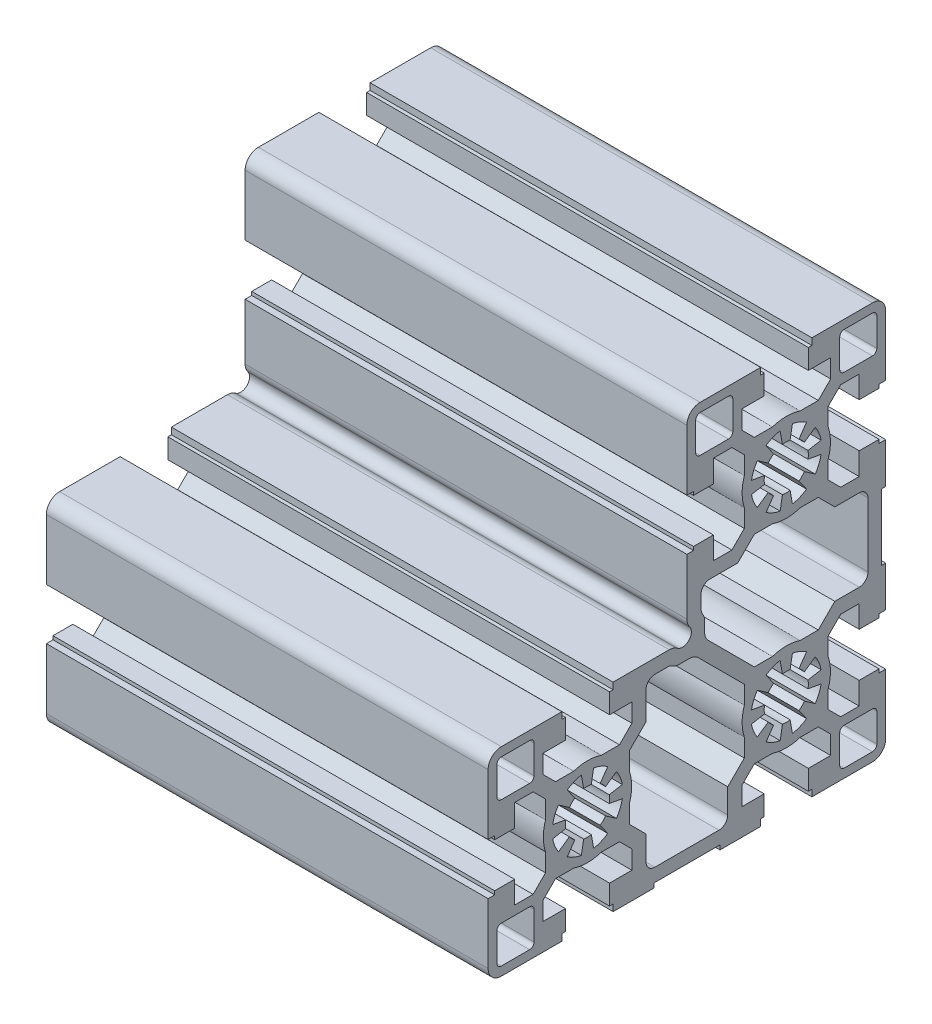
from build123d import *

# Parameters (mm, degrees)
EXTRUDE_1_DEPTH = 100


with BuildPart() as part:
    # Эскиз2 → Бобышка-Вытянуть1 (new body)
    with BuildSketch(Plane(origin=(0, 0, 0), x_dir=(0, 0, -1), z_dir=(1, 0, 0))):
        with BuildLine():
            Line((-67.500000003, -19.500000001), (-67.500000003, -5.800000001))
            Line((-67.500000003, -5.800000001), (-66.000000006, -5.800000001))
            Line((-66.000000006, -5.800000001), (-66.000000006, -5))
            Line((-66.000000006, -5), (-61.500000006, -5))
            Line((-61.500000006, -5), (-61.500000006, -10.05))
            Line((-61.500000006, -10.05), (-57.312741706, -10.05))
            Line((-57.312741706, -10.05), (-54.500000006, -7.2372583))
            Line((-54.500000006, -7.2372583), (-54.500000006, -3.122499))
            ThreePointArc((-54.500000006, -3.122499), (-55.000000006, 0), (-54.500000006, 3.122499))
            Line((-54.500000006, 3.122499), (-54.500000006, 7.2372583))
            Line((-54.500000006, 7.2372583), (-57.312741706, 10.05))
            Line((-57.312741706, 10.05), (-61.500000006, 10.05))
            Line((-61.500000006, 10.05), (-61.500000006, 4.999999999))
            Line((-61.500000006, 4.999999999), (-66.000000006, 4.999999999))
            Line((-66.000000006, 4.999999999), (-66.000000006, 5.799999999))
            Line((-66.000000006, 5.799999999), (-67.500000003, 5.799999999))
            Line((-67.500000003, 5.799999999), (-67.500000003, 19.499999999))
            ThreePointArc((-67.500000003, 19.499999999), (-66.621320347, 21.621320343), (-64.500000003, 22.499999999))
            Line((-64.500000003, 22.499999999), (-50.800000006, 22.499999999))
            Line((-50.800000006, 22.499999999), (-50.800000006, 21))
            Line((-50.800000006, 21), (-50.000000006, 21))
            Line((-50.000000006, 21), (-50.000000006, 16.5))
            Line((-50.000000006, 16.5), (-55.050000006, 16.5))
            Line((-55.050000006, 16.5), (-55.050000006, 12.3127417))
            Line((-55.050000006, 12.3127417), (-52.237258306, 9.5))
            Line((-52.237258306, 9.5), (-48.122499006, 9.5))
            ThreePointArc((-48.122499006, 9.5), (-45.000000006, 10), (-41.877501006, 9.5))
            Line((-41.877501006, 9.5), (-37.762741706, 9.5))
            Line((-37.762741706, 9.5), (-34.950000006, 12.3127417))
            Line((-34.950000006, 12.3127417), (-34.950000006, 16.5))
            Line((-34.950000006, 16.5), (-40.000000006, 16.5))
            Line((-40.000000006, 16.5), (-40.000000006, 21))
            Line((-40.000000006, 21), (-39.200000006, 21))
            Line((-39.200000006, 21), (-39.200000006, 22.5))
            Line((-39.200000006, 22.5), (-26.503303616, 22.5))
            ThreePointArc((-26.503303616, 22.5), (-25.549864863, 22.344460326), (-24.695291146, 21.893969697))
            ThreePointArc((-24.695291146, 21.893969697), (-22.075735937, 22.075735932), (-21.8939697, 24.695291141))
            ThreePointArc((-21.8939697, 24.695291141), (-22.344460329, 25.549864857), (-22.500000002, 26.503303609))
            Line((-22.500000002, 26.503303609), (-22.500000002, 39.199999999))
            Line((-22.500000002, 39.199999999), (-21, 39.199999999))
            Line((-21, 39.199999999), (-21, 39.999999998))
            Line((-21, 39.999999998), (-16.500000023, 39.999999998))
            Line((-16.500000023, 39.999999998), (-16.500000023, 34.949999998))
            Line((-16.500000023, 34.949999998), (-12.312741723, 34.949999998))
            Line((-12.312741723, 34.949999998), (-9.500000023, 37.762741698))
            Line((-9.500000023, 37.762741698), (-9.500000023, 41.877500998))
            ThreePointArc((-9.500000023, 41.877500998), (-10.000000023, 44.999999998), (-9.500000023, 48.122498998))
            Line((-9.500000023, 48.122498998), (-9.500000023, 52.237258298))
            Line((-9.500000023, 52.237258298), (-12.312741723, 55.049999998))
            Line((-12.312741723, 55.049999998), (-16.500000003, 55.049999998))
            Line((-16.500000003, 55.049999998), (-16.500000003, 49.999999999))
            Line((-16.500000003, 49.999999999), (-21.000000003, 49.999999999))
            Line((-21.000000003, 49.999999999), (-21.000000003, 50.799999999))
            Line((-21.000000003, 50.799999999), (-22.500000003, 50.799999999))
            Line((-22.500000003, 50.799999999), (-22.500000003, 64.499999999))
            ThreePointArc((-22.500000003, 64.499999999), (-21.621320347, 66.621320343), (-19.500000003, 67.499999999))
            Line((-19.500000003, 67.499999999), (-5.800000023, 67.499999999))
            Line((-5.800000023, 67.499999999), (-5.800000023, 65.999999998))
            Line((-5.800000023, 65.999999998), (-5.000000023, 65.999999998))
            Line((-5.000000023, 65.999999998), (-5.000000023, 61.499999998))
            Line((-5.000000023, 61.499999998), (-10.050000023, 61.499999998))
            Line((-10.050000023, 61.499999998), (-10.050000023, 57.312741698))
            Line((-10.050000023, 57.312741698), (-7.237258323, 54.499999998))
            Line((-7.237258323, 54.499999998), (-3.122499023, 54.499999998))
            ThreePointArc((-3.122499023, 54.499999998), (-2.3e-08, 54.999999999), (3.122498977, 54.499999998))
            Line((3.122498977, 54.499999998), (7.237258277, 54.499999998))
            Line((7.237258277, 54.499999998), (10.049999977, 57.312741698))
            Line((10.049999977, 57.312741698), (10.049999977, 61.499999998))
            Line((10.049999977, 61.499999998), (4.999999977, 61.499999998))
            Line((4.999999977, 61.499999998), (4.999999977, 65.999999998))
            Line((4.999999977, 65.999999998), (5.799999977, 65.999999998))
            Line((5.799999977, 65.999999998), (5.799999977, 67.499999999))
            Line((5.799999977, 67.499999999), (19.499999997, 67.499999999))
            ThreePointArc((19.499999997, 67.499999999), (21.621320341, 66.621320343), (22.499999997, 64.499999999))
            Line((22.499999997, 64.499999999), (22.499999997, 50.799999999))
            Line((22.499999997, 50.799999999), (20.999999997, 50.799999999))
            Line((20.999999997, 50.799999999), (20.999999997, 49.999999999))
            Line((20.999999997, 49.999999999), (16.499999997, 49.999999999))
            Line((16.499999997, 49.999999999), (16.499999997, 55.049999998))
            Line((16.499999997, 55.049999998), (12.312741677, 55.049999998))
            Line((12.312741677, 55.049999998), (9.499999977, 52.237258298))
            Line((9.499999977, 52.237258298), (9.499999977, 48.122498998))
            ThreePointArc((9.499999977, 48.122498998), (9.999999977, 44.999999998), (9.499999977, 41.877500998))
            Line((9.499999977, 41.877500998), (9.499999977, 37.762741698))
            Line((9.499999977, 37.762741698), (12.312741677, 34.949999998))
            Line((12.312741677, 34.949999998), (16.499999977, 34.949999998))
            Line((16.499999977, 34.949999998), (16.499999977, 40))
            Line((16.499999977, 40), (21, 40))
            Line((21, 40), (21, 39.2))
            Line((21, 39.2), (22.5, 39.2))
            Line((22.5, 39.2), (22.5, 30))
            Line((22.5, 30), (21.5, 30))
            Line((21.5, 30), (21.5, 15))
            Line((21.5, 15), (22.5, 15))
            Line((22.5, 15), (22.5, 5.8))
            Line((22.5, 5.8), (21, 5.8))
            Line((21, 5.8), (21, 5))
            Line((21, 5), (16.5, 5))
            Line((16.5, 5), (16.5, 10.05))
            Line((16.5, 10.05), (12.3127417, 10.05))
            Line((12.3127417, 10.05), (9.5, 7.2372583))
            Line((9.5, 7.2372583), (9.5, 3.122499))
            ThreePointArc((9.5, 3.122499), (10, 0), (9.5, -3.122499))
            Line((9.5, -3.122499), (9.5, -7.2372583))
            Line((9.5, -7.2372583), (12.3127417, -10.05))
            Line((12.3127417, -10.05), (16.5, -10.05))
            Line((16.5, -10.05), (16.5, -5.000000001))
            Line((16.5, -5.000000001), (20.999999997, -5.000000001))
            Line((20.999999997, -5.000000001), (20.999999997, -5.800000001))
            Line((20.999999997, -5.800000001), (22.499999997, -5.800000001))
            Line((22.499999997, -5.800000001), (22.499999997, -19.500000001))
            ThreePointArc((22.499999997, -19.500000001), (21.621320341, -21.621320345), (19.499999997, -22.500000001))
            Line((19.499999997, -22.500000001), (5.799999997, -22.500000001))
            Line((5.799999997, -22.500000001), (5.799999997, -21.000000001))
            Line((5.799999997, -21.000000001), (4.999999997, -21.000000001))
            Line((4.999999997, -21.000000001), (4.999999997, -16.5))
            Line((4.999999997, -16.5), (10.05, -16.5))
            Line((10.05, -16.5), (10.05, -12.3127417))
            Line((10.05, -12.3127417), (7.2372583, -9.5))
            Line((7.2372583, -9.5), (3.122499, -9.5))
            ThreePointArc((3.122499, -9.5), (0, -10), (-3.122499, -9.5))
            Line((-3.122499, -9.5), (-7.2372583, -9.5))
            Line((-7.2372583, -9.5), (-10.05, -12.3127417))
            Line((-10.05, -12.3127417), (-10.05, -16.5))
            Line((-10.05, -16.5), (-5, -16.5))
            Line((-5, -16.5), (-5, -21))
            Line((-5, -21), (-5.8, -21))
            Line((-5.8, -21), (-5.8, -22.5))
            Line((-5.8, -22.5), (-15, -22.5))
            Line((-15, -22.5), (-15, -21.5))
            Line((-15, -21.5), (-30, -21.5))
            Line((-30, -21.5), (-30, -22.5))
            Line((-30, -22.5), (-39.2, -22.5))
            Line((-39.2, -22.5), (-39.2, -21))
            Line((-39.2, -21), (-40, -21))
            Line((-40, -21), (-40, -16.5))
            Line((-40, -16.5), (-34.950000006, -16.5))
            Line((-34.950000006, -16.5), (-34.950000006, -12.3127417))
            Line((-34.950000006, -12.3127417), (-37.762741706, -9.5))
            Line((-37.762741706, -9.5), (-41.877501006, -9.5))
            ThreePointArc((-41.877501006, -9.5), (-45.000000006, -10), (-48.122499006, -9.5))
            Line((-48.122499006, -9.5), (-52.237258306, -9.5))
            Line((-52.237258306, -9.5), (-55.050000006, -12.3127417))
            Line((-55.050000006, -12.3127417), (-55.050000006, -16.500000001))
            Line((-55.050000006, -16.500000001), (-50.000000003, -16.500000001))
            Line((-50.000000003, -16.500000001), (-50.000000003, -21.000000001))
            Line((-50.000000003, -21.000000001), (-50.800000003, -21.000000001))
            Line((-50.800000003, -21.000000001), (-50.800000003, -22.500000001))
            Line((-50.800000003, -22.500000001), (-64.500000003, -22.500000001))
            ThreePointArc((-64.500000003, -22.500000001), (-66.621320347, -21.621320345), (-67.500000003, -19.500000001))
        make_face()
        with BuildLine():
            Line((13.099999997, 65.499999999), (19.499999997, 65.499999999))
            ThreePointArc((19.499999997, 65.499999999), (20.207106778, 65.20710678), (20.499999997, 64.499999999))
            Line((20.499999997, 64.499999999), (20.499999997, 58.099999999))
            ThreePointArc((20.499999997, 58.099999999), (20.207106778, 57.392893218), (19.499999997, 57.099999999))
            Line((19.499999997, 57.099999999), (13.099999997, 57.099999999))
            ThreePointArc((13.099999997, 57.099999999), (12.392893216, 57.392893218), (12.099999997, 58.099999999))
            Line((12.099999997, 58.099999999), (12.099999997, 64.499999999))
            ThreePointArc((12.099999997, 64.499999999), (12.392893216, 65.20710678), (13.099999997, 65.499999999))
        make_face(mode=Mode.SUBTRACT)
        with BuildLine():
            Line((-18.763513725, 25.405955913), (-19.036486289, 25.883657888))
            ThreePointArc((-19.036486289, 25.883657888), (-19.232999307, 26.362599899), (-19.300000011, 26.875935775))
            Line((-19.300000011, 26.875935775), (-19.300000011, 29.749569695))
            ThreePointArc((-19.300000011, 29.749569695), (-18.714213574, 31.163783257), (-17.300000012, 31.749569695))
            Line((-17.300000012, 31.749569695), (-10.987688612, 31.749569695))
            Line((-10.987688612, 31.749569695), (-7.237258312, 35.499999995))
            Line((-7.237258312, 35.499999995), (-3.122499012, 35.499999995))
            ThreePointArc((-3.122499012, 35.499999995), (-1e-08, 34.999999998), (3.122498991, 35.500000003))
            Line((3.122498991, 35.500000003), (7.237258291, 35.500000003))
            Line((7.237258291, 35.500000003), (10.987688591, 31.749569703))
            Line((10.987688591, 31.749569703), (16.499999991, 31.749569703))
            ThreePointArc((16.499999991, 31.749569703), (17.914213553, 31.163783265), (18.499999991, 29.749569703))
            Line((18.499999991, 29.749569703), (18.499999991, 15.250000003))
            ThreePointArc((18.499999991, 15.250000003), (17.914213553, 13.835786441), (16.499999991, 13.250000003))
            Line((16.499999991, 13.250000003), (10.987258291, 13.250000003))
            Line((10.987258291, 13.250000003), (7.237258291, 9.500000003))
            Line((7.237258291, 9.500000003), (3.122498991, 9.500000003))
            ThreePointArc((3.122498991, 9.500000003), (-9e-09, 10), (-3.122499009, 9.499999997))
            Line((-3.122499009, 9.499999997), (-7.237258309, 9.499999997))
            Line((-7.237258309, 9.499999997), (-17.621320349, 19.884062037))
            ThreePointArc((-17.621320349, 19.884062037), (-18.271638602, 20.857332083), (-18.500000003, 22.00538238))
            Line((-18.500000003, 22.00538238), (-18.500000003, 24.413678025))
            ThreePointArc((-18.500000003, 24.413678025), (-18.567000707, 24.927013902), (-18.763513725, 25.405955913))
        make_face(mode=Mode.SUBTRACT)
        with BuildLine():
            Line((-7.878462043, 43.610814578), (-4.924038783, 44.131759108))
            ThreePointArc((-4.924038783, 44.131759108), (-5.000000018, 44.999999998), (-4.924038783, 45.868240888))
            Line((-4.924038783, 45.868240888), (-7.878462043, 46.389185418))
            ThreePointArc((-7.878462043, 46.389185418), (-7.391036279, 48.061467456), (-6.553216373, 49.588611488))
            Line((-6.553216373, 49.588611488), (-4.095760243, 47.867882178))
            ThreePointArc((-4.095760243, 47.867882178), (-3.535533927, 48.535533903), (-2.867882203, 49.095760218))
            Line((-2.867882203, 49.095760218), (-4.588611513, 51.553216348))
            ThreePointArc((-4.588611513, 51.553216348), (-3.061467481, 52.391036255), (-1.389185443, 52.878462019))
            Line((-1.389185443, 52.878462019), (-0.868240913, 49.924038758))
            ThreePointArc((-0.868240913, 49.924038758), (-2.3e-08, 49.999999994), (0.868240867, 49.924038758))
            Line((0.868240867, 49.924038758), (1.389185397, 52.878462018))
            ThreePointArc((1.389185397, 52.878462018), (3.061467435, 52.391036254), (4.588611467, 51.553216348))
            Line((4.588611467, 51.553216348), (2.867882157, 49.095760218))
            ThreePointArc((2.867882157, 49.095760218), (3.535533882, 48.535533903), (4.095760197, 47.867882178))
            Line((4.095760197, 47.867882178), (6.553216327, 49.588611488))
            ThreePointArc((6.553216327, 49.588611488), (7.391036233, 48.061467456), (7.878461997, 46.389185418))
            Line((7.878461997, 46.389185418), (4.924038737, 45.868240888))
            ThreePointArc((4.924038737, 45.868240888), (4.999999972, 44.999999998), (4.924038737, 44.131759108))
            Line((4.924038737, 44.131759108), (7.878461997, 43.610814578))
            ThreePointArc((7.878461997, 43.610814578), (7.391036233, 41.938532541), (6.553216327, 40.411388509))
            Line((6.553216327, 40.411388509), (4.095760197, 42.132117818))
            ThreePointArc((4.095760197, 42.132117818), (3.535533882, 41.464466094), (2.867882157, 40.904239778))
            Line((2.867882157, 40.904239778), (4.588611467, 38.446783648))
            ThreePointArc((4.588611467, 38.446783648), (3.061467435, 37.608963742), (1.389185397, 37.121537978))
            Line((1.389185397, 37.121537978), (0.868240867, 40.075961238))
            ThreePointArc((0.868240867, 40.075961238), (-2.3e-08, 40.000000003), (-0.868240913, 40.075961238))
            Line((-0.868240913, 40.075961238), (-1.389185443, 37.121537978))
            ThreePointArc((-1.389185443, 37.121537978), (-3.061467481, 37.608963743), (-4.588611513, 38.446783649))
            Line((-4.588611513, 38.446783649), (-2.867882203, 40.904239778))
            ThreePointArc((-2.867882203, 40.904239778), (-3.535533927, 41.464466094), (-4.095760243, 42.132117818))
            Line((-4.095760243, 42.132117818), (-6.553216373, 40.411388508))
            ThreePointArc((-6.553216373, 40.411388508), (-7.391036279, 41.93853254), (-7.878462043, 43.610814578))
        make_face(mode=Mode.SUBTRACT)
        with BuildLine():
            Line((-20.500000003, 58.099999999), (-20.500000003, 64.499999999))
            ThreePointArc((-20.500000003, 64.499999999), (-20.207106784, 65.20710678), (-19.500000003, 65.499999999))
            Line((-19.500000003, 65.499999999), (-13.100000003, 65.499999999))
            ThreePointArc((-13.100000003, 65.499999999), (-12.392893222, 65.20710678), (-12.100000003, 64.499999999))
            Line((-12.100000003, 64.499999999), (-12.100000003, 58.099999999))
            ThreePointArc((-12.100000003, 58.099999999), (-12.392893222, 57.392893218), (-13.100000003, 57.099999999))
            Line((-13.100000003, 57.099999999), (-19.500000003, 57.099999999))
            ThreePointArc((-19.500000003, 57.099999999), (-20.207106784, 57.392893218), (-20.500000003, 58.099999999))
        make_face(mode=Mode.SUBTRACT)
        with BuildLine():
            Line((-57.100000003, 19.499999999), (-57.100000003, 13.099999999))
            ThreePointArc((-57.100000003, 13.099999999), (-57.392893222, 12.392893218), (-58.100000003, 12.099999999))
            Line((-58.100000003, 12.099999999), (-64.500000003, 12.099999999))
            ThreePointArc((-64.500000003, 12.099999999), (-65.207106784, 12.392893218), (-65.500000003, 13.099999999))
            Line((-65.500000003, 13.099999999), (-65.500000003, 19.499999999))
            ThreePointArc((-65.500000003, 19.499999999), (-65.207106784, 20.20710678), (-64.500000003, 20.499999999))
            Line((-64.500000003, 20.499999999), (-58.100000003, 20.499999999))
            ThreePointArc((-58.100000003, 20.499999999), (-57.392893222, 20.20710678), (-57.100000003, 19.499999999))
        make_face(mode=Mode.SUBTRACT)
        with BuildLine():
            Line((-52.878462026, -1.38918542), (-49.924038766, -0.86824089))
            ThreePointArc((-49.924038766, -0.86824089), (-50.000000001, 0), (-49.924038766, 0.86824089))
            Line((-49.924038766, 0.86824089), (-52.878462026, 1.38918542))
            ThreePointArc((-52.878462026, 1.38918542), (-52.391036262, 3.061467458), (-51.553216356, 4.58861149))
            Line((-51.553216356, 4.58861149), (-49.095760226, 2.86788218))
            ThreePointArc((-49.095760226, 2.86788218), (-48.53553391, 3.535533904), (-47.867882186, 4.09576022))
            Line((-47.867882186, 4.09576022), (-49.588611496, 6.55321635))
            ThreePointArc((-49.588611496, 6.55321635), (-48.061467464, 7.391036256), (-46.389185426, 7.87846202))
            Line((-46.389185426, 7.87846202), (-45.868240896, 4.92403876))
            ThreePointArc((-45.868240896, 4.92403876), (-45.000000006, 4.999999995), (-44.131759116, 4.92403876))
            Line((-44.131759116, 4.92403876), (-43.610814586, 7.87846202))
            ThreePointArc((-43.610814586, 7.87846202), (-41.938532548, 7.391036256), (-40.411388516, 6.55321635))
            Line((-40.411388516, 6.55321635), (-42.132117826, 4.09576022))
            ThreePointArc((-42.132117826, 4.09576022), (-41.464466102, 3.535533904), (-40.904239786, 2.86788218))
            Line((-40.904239786, 2.86788218), (-38.446783656, 4.58861149))
            ThreePointArc((-38.446783656, 4.58861149), (-37.60896375, 3.061467458), (-37.121537986, 1.38918542))
            Line((-37.121537986, 1.38918542), (-40.075961246, 0.86824089))
            ThreePointArc((-40.075961246, 0.86824089), (-40.000000011, 0), (-40.075961246, -0.86824089))
            Line((-40.075961246, -0.86824089), (-37.121537986, -1.38918542))
            ThreePointArc((-37.121537986, -1.38918542), (-37.60896375, -3.061467458), (-38.446783656, -4.58861149))
            Line((-38.446783656, -4.58861149), (-40.904239786, -2.86788218))
            ThreePointArc((-40.904239786, -2.86788218), (-41.464466102, -3.535533904), (-42.132117826, -4.09576022))
            Line((-42.132117826, -4.09576022), (-40.411388516, -6.55321635))
            ThreePointArc((-40.411388516, -6.55321635), (-41.938532548, -7.391036256), (-43.610814586, -7.87846202))
            Line((-43.610814586, -7.87846202), (-44.131759116, -4.92403876))
            ThreePointArc((-44.131759116, -4.92403876), (-45.000000006, -4.999999995), (-45.868240896, -4.92403876))
            Line((-45.868240896, -4.92403876), (-46.389185426, -7.87846202))
            ThreePointArc((-46.389185426, -7.87846202), (-48.061467464, -7.391036256), (-49.588611496, -6.55321635))
            Line((-49.588611496, -6.55321635), (-47.867882186, -4.09576022))
            ThreePointArc((-47.867882186, -4.09576022), (-48.53553391, -3.535533904), (-49.095760226, -2.86788218))
            Line((-49.095760226, -2.86788218), (-51.553216356, -4.58861149))
            ThreePointArc((-51.553216356, -4.58861149), (-52.391036262, -3.061467458), (-52.878462026, -1.38918542))
        make_face(mode=Mode.SUBTRACT)
        with BuildLine():
            Line((-19.884062037, 17.621320349), (-9.499999997, 7.237258309))
            Line((-9.499999997, 7.237258309), (-9.499999997, 3.122499009))
            ThreePointArc((-9.499999997, 3.122499009), (-10, 9e-09), (-9.500000003, -3.122498991))
            Line((-9.500000003, -3.122498991), (-9.500000003, -7.237258291))
            Line((-9.500000003, -7.237258291), (-13.250000003, -10.987258291))
            Line((-13.250000003, -10.987258291), (-13.250000003, -16.499999991))
            ThreePointArc((-13.250000003, -16.499999991), (-13.835786441, -17.914213553), (-15.250000003, -18.499999991))
            Line((-15.250000003, -18.499999991), (-29.749569703, -18.499999991))
            ThreePointArc((-29.749569703, -18.499999991), (-31.163783265, -17.914213553), (-31.749569703, -16.499999991))
            Line((-31.749569703, -16.499999991), (-31.749569703, -10.987688591))
            Line((-31.749569703, -10.987688591), (-35.500000003, -7.237258291))
            Line((-35.500000003, -7.237258291), (-35.500000003, -3.122498991))
            ThreePointArc((-35.500000003, -3.122498991), (-35.000000006, 9e-09), (-35.500000009, 3.122499009))
            Line((-35.500000009, 3.122499009), (-35.500000009, 7.237258309))
            Line((-35.500000009, 7.237258309), (-31.749569709, 10.987688609))
            Line((-31.749569709, 10.987688609), (-31.749569709, 17.300000009))
            ThreePointArc((-31.749569709, 17.300000009), (-31.163783271, 18.714213571), (-29.749569709, 19.300000009))
            Line((-29.749569709, 19.300000009), (-26.875935789, 19.300000009))
            ThreePointArc((-26.875935789, 19.300000009), (-26.362599913, 19.232999305), (-25.883657901, 19.036486287))
            Line((-25.883657901, 19.036486287), (-25.405955926, 18.763513723))
            ThreePointArc((-25.405955926, 18.763513723), (-24.927013909, 18.567000705), (-24.413678026, 18.500000004))
            Line((-24.413678026, 18.500000004), (-22.005382376, 18.500000004))
            ThreePointArc((-22.005382376, 18.500000004), (-20.857332081, 18.271638602), (-19.884062037, 17.621320349))
        make_face(mode=Mode.SUBTRACT)
        with BuildLine():
            Line((-7.87846202, -1.38918542), (-4.92403876, -0.86824089))
            ThreePointArc((-4.92403876, -0.86824089), (-4.999999995, 0), (-4.92403876, 0.86824089))
            Line((-4.92403876, 0.86824089), (-7.87846202, 1.38918542))
            ThreePointArc((-7.87846202, 1.38918542), (-7.391036256, 3.061467458), (-6.55321635, 4.58861149))
            Line((-6.55321635, 4.58861149), (-4.09576022, 2.86788218))
            ThreePointArc((-4.09576022, 2.86788218), (-3.535533904, 3.535533904), (-2.86788218, 4.09576022))
            Line((-2.86788218, 4.09576022), (-4.58861149, 6.55321635))
            ThreePointArc((-4.58861149, 6.55321635), (-3.061467458, 7.391036256), (-1.38918542, 7.87846202))
            Line((-1.38918542, 7.87846202), (-0.86824089, 4.92403876))
            ThreePointArc((-0.86824089, 4.92403876), (0, 4.999999995), (0.86824089, 4.92403876))
            Line((0.86824089, 4.92403876), (1.38918542, 7.87846202))
            ThreePointArc((1.38918542, 7.87846202), (3.061467458, 7.391036256), (4.58861149, 6.55321635))
            Line((4.58861149, 6.55321635), (2.86788218, 4.09576022))
            ThreePointArc((2.86788218, 4.09576022), (3.535533904, 3.535533904), (4.09576022, 2.86788218))
            Line((4.09576022, 2.86788218), (6.55321635, 4.58861149))
            ThreePointArc((6.55321635, 4.58861149), (7.391036256, 3.061467458), (7.87846202, 1.38918542))
            Line((7.87846202, 1.38918542), (4.92403876, 0.86824089))
            ThreePointArc((4.92403876, 0.86824089), (4.999999995, 0), (4.92403876, -0.86824089))
            Line((4.92403876, -0.86824089), (7.87846202, -1.38918542))
            ThreePointArc((7.87846202, -1.38918542), (7.391036256, -3.061467458), (6.55321635, -4.58861149))
            Line((6.55321635, -4.58861149), (4.09576022, -2.86788218))
            ThreePointArc((4.09576022, -2.86788218), (3.535533904, -3.535533904), (2.86788218, -4.09576022))
            Line((2.86788218, -4.09576022), (4.58861149, -6.55321635))
            ThreePointArc((4.58861149, -6.55321635), (3.061467458, -7.391036256), (1.38918542, -7.87846202))
            Line((1.38918542, -7.87846202), (0.86824089, -4.92403876))
            ThreePointArc((0.86824089, -4.92403876), (0, -4.999999995), (-0.86824089, -4.92403876))
            Line((-0.86824089, -4.92403876), (-1.38918542, -7.87846202))
            ThreePointArc((-1.38918542, -7.87846202), (-3.061467458, -7.391036256), (-4.58861149, -6.55321635))
            Line((-4.58861149, -6.55321635), (-2.86788218, -4.09576022))
            ThreePointArc((-2.86788218, -4.09576022), (-3.535533904, -3.535533904), (-4.09576022, -2.86788218))
            Line((-4.09576022, -2.86788218), (-6.55321635, -4.58861149))
            ThreePointArc((-6.55321635, -4.58861149), (-7.391036256, -3.061467458), (-7.87846202, -1.38918542))
        make_face(mode=Mode.SUBTRACT)
        with BuildLine():
            Line((-58.100000003, -20.500000001), (-64.500000003, -20.500000001))
            ThreePointArc((-64.500000003, -20.500000001), (-65.207106784, -20.207106782), (-65.500000003, -19.500000001))
            Line((-65.500000003, -19.500000001), (-65.500000003, -13.100000001))
            ThreePointArc((-65.500000003, -13.100000001), (-65.207106784, -12.39289322), (-64.500000003, -12.100000001))
            Line((-64.500000003, -12.100000001), (-58.100000003, -12.100000001))
            ThreePointArc((-58.100000003, -12.100000001), (-57.392893222, -12.39289322), (-57.100000003, -13.100000001))
            Line((-57.100000003, -13.100000001), (-57.100000003, -19.500000001))
            ThreePointArc((-57.100000003, -19.500000001), (-57.392893222, -20.207106782), (-58.100000003, -20.500000001))
        make_face(mode=Mode.SUBTRACT)
        with BuildLine():
            Line((20.499999997, -13.100000001), (20.499999997, -19.500000001))
            ThreePointArc((20.499999997, -19.500000001), (20.207106778, -20.207106782), (19.499999997, -20.500000001))
            Line((19.499999997, -20.500000001), (13.099999997, -20.500000001))
            ThreePointArc((13.099999997, -20.500000001), (12.392893216, -20.207106782), (12.099999997, -19.500000001))
            Line((12.099999997, -19.500000001), (12.099999997, -13.100000001))
            ThreePointArc((12.099999997, -13.100000001), (12.392893216, -12.39289322), (13.099999997, -12.100000001))
            Line((13.099999997, -12.100000001), (19.499999997, -12.100000001))
            ThreePointArc((19.499999997, -12.100000001), (20.207106778, -12.39289322), (20.499999997, -13.100000001))
        make_face(mode=Mode.SUBTRACT)
    extrude(amount=-EXTRUDE_1_DEPTH)


solid = part.part
